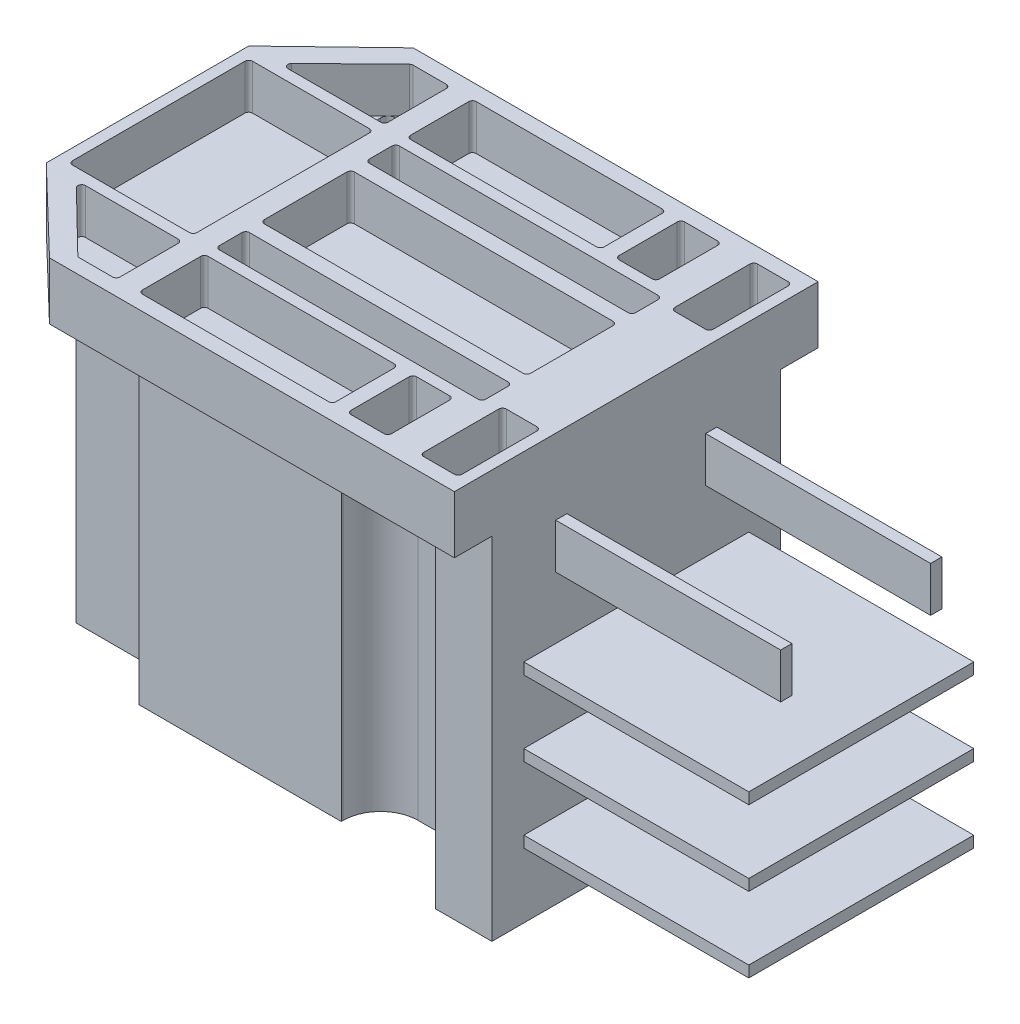
from build123d import *

# Parameters (mm, degrees)
SKETCH_1_W          = 65.18
SKETCH_1_H          = 48.5
EXTRUDE_1_DEPTH     = 7.64
SKETCH_2_W          = 5
SKETCH_2_H          = 4
CUT_EXTRUDE_1_DEPTH = 8.64
FILLET_1_R          = 1
CUT_EXTRUDE_2_DEPTH = 8.64
EXTRUDE_2_DEPTH     = 42
SKETCH_5_W          = 7.5
SKETCH_5_H          = 38.5
EXTRUDE_3_DEPTH     = 46.8
FILLET_2_R          = 5
SKETCH_6_W          = 30
SKETCH_6_H          = 1.5
SKETCH_6_W_2        = 1.5
SKETCH_6_H_2        = 6
EXTRUDE_4_DEPTH     = 30
SKETCH_8_W          = 16.59
SKETCH_8_H          = 24
SKETCH_8_W_2        = 5.4
SKETCH_8_H_2        = 8.75
SKETCH_8_W_3        = 35.5
SKETCH_8_H_3        = 12
SKETCH_8_W_4        = 25.8
SKETCH_8_H_4        = 4
SKETCH_8_W_5        = 5.09
SKETCH_8_H_5        = 11
CUT_EXTRUDE_3_DEPTH = 6
FILLET_3_R          = 0.5


with BuildPart() as part:
    # 草图1 → 凸台-拉伸1 (new body)
    with BuildSketch(Plane(origin=(0, 0, 0), x_dir=(1, 0, 0), z_dir=(0, 1, 0))):
        Rectangle(SKETCH_1_W, SKETCH_1_H)
    extrude(amount=EXTRUDE_1_DEPTH)

    # 草图2 → 切除-拉伸1 (cut, through all)
    with BuildSketch(Plane(origin=(0, 7.64, 0), x_dir=(1, 0, 0), z_dir=(0, 1, 0))):
        with Locations((19, 19)):
            Rectangle(SKETCH_2_W, SKETCH_2_H)
        with Locations((-19, 19)):
            Rectangle(SKETCH_2_W, SKETCH_2_H)
        with Locations((19, -19)):
            Rectangle(SKETCH_2_W, SKETCH_2_H)
        with Locations((-19, -19)):
            Rectangle(SKETCH_2_W, SKETCH_2_H)
    extrude(amount=-CUT_EXTRUDE_1_DEPTH, mode=Mode.SUBTRACT)

    # 圆角1
    fillet_1_edges = [part.edges().sort_by_distance(p)[0] for p in [
        (-16.5, 3.82, 17),
        (-16.5, 3.82, 21),
        (-21.5, 3.82, 21),
        (-21.5, 3.82, 17),
        (16.5, 3.82, 17),
        (21.5, 3.82, 17),
        (21.5, 3.82, 21),
        (16.5, 3.82, 21),
        (16.5, 3.82, -17),
        (16.5, 3.82, -21),
        (21.5, 3.82, -21),
        (21.5, 3.82, -17),
        (-21.5, 3.82, -17),
        (-21.5, 3.82, -21),
        (-16.5, 3.82, -21),
        (-16.5, 3.82, -17),
    ]]
    fillet(fillet_1_edges, radius=FILLET_1_R)

    # 草图3 → 切除-拉伸2 (cut, through all)
    with BuildSketch(Plane(origin=(0, 7.64, 0), x_dir=(1, 0, 0), z_dir=(0, 1, 0))):
        Polygon((-21.41, 24.25), (-32.59, 13.5), (-32.59, 24.25), align=None)
        Polygon((-32.59, -13.5), (-32.59, -24.25), (-21.41, -24.25), align=None)
    extrude(amount=-CUT_EXTRUDE_2_DEPTH, mode=Mode.SUBTRACT)

    # 草图4 → 凸台-拉伸2 (add)
    with BuildSketch(Plane.XZ):
        Polygon((-27.09, -15), (-27.09, 15), (-13.5, 15), (-13.5, 20.25), (13.5, 20.25), (13.5, 15), (25.09, 15), (25.09, -15), (13.5, -15), (13.5, -20.25), (-13.5, -20.25), (-13.5, -15), align=None)
    extrude(amount=EXTRUDE_2_DEPTH)

    # 草图5 → 凸台-拉伸3 (add)
    with BuildSketch(Plane.XZ):
        with Locations((28.84, 0)):
            Rectangle(SKETCH_5_W, SKETCH_5_H)
    extrude(amount=EXTRUDE_3_DEPTH)

    # 圆角2
    fillet_2_edges = [part.edges().sort_by_distance(p)[0] for p in [
        (-13.5, -21, 15),
        (-13.5, -21, -15),
        (13.5, -21, -15),
        (13.5, -21, 15),
    ]]
    fillet(fillet_2_edges, radius=FILLET_2_R)

    # 草图6 → 凸台-拉伸4 (add)
    with BuildSketch(Plane(origin=(32.59, 0, 0), x_dir=(0, 0, -1), z_dir=(1, 0, 0))):
        with Locations((0, -27.4)):
            Rectangle(SKETCH_6_W, SKETCH_6_H)
        with Locations((0, -17.4)):
            Rectangle(SKETCH_6_W, SKETCH_6_H)
        with Locations((0, -37.4)):
            Rectangle(SKETCH_6_W, SKETCH_6_H)
        with Locations((10, -5.4)):
            Rectangle(SKETCH_6_W_2, SKETCH_6_H_2)
        with Locations((-10, -5.4)):
            Rectangle(SKETCH_6_W_2, SKETCH_6_H_2)
    extrude(amount=EXTRUDE_4_DEPTH)

    # 草图8 → 切除-拉伸3 (cut)
    with BuildSketch(Plane(origin=(0, 7.64, 0), x_dir=(1, 0, 0), z_dir=(0, 1, 0))):
        Polygon((-28.59, 13.5), (-14.5, 13.5), (-14.5, 22.25), (-19.626707293, 22.25), align=None)
        with Locations((-22.795, 0)):
            Rectangle(SKETCH_8_W, SKETCH_8_H)
        with Locations((19, 17.875)):
            Rectangle(SKETCH_8_W_2, SKETCH_8_H_2)
        with Locations((6.25, 0)):
            Rectangle(SKETCH_8_W_3, SKETCH_8_H_3)
        with Locations((1.4, 17.875)):
            Rectangle(SKETCH_8_W_4, SKETCH_8_H_2)
        with Locations((6.25, 10)):
            Rectangle(SKETCH_8_W_3, SKETCH_8_H_4)
        with Locations((28.545, 16.75)):
            Rectangle(SKETCH_8_W_5, SKETCH_8_H_5)
        with Locations((28.545, -16.75)):
            Rectangle(SKETCH_8_W_5, SKETCH_8_H_5)
        with Locations((19, -17.875)):
            Rectangle(SKETCH_8_W_2, SKETCH_8_H_2)
        with Locations((6.25, -10)):
            Rectangle(SKETCH_8_W_3, SKETCH_8_H_4)
        with Locations((1.4, -17.875)):
            Rectangle(SKETCH_8_W_4, SKETCH_8_H_2)
        Polygon((-14.5, -22.25), (-19.626707293, -22.25), (-28.59, -13.5), (-14.5, -13.5), align=None)
    extrude(amount=-CUT_EXTRUDE_3_DEPTH, mode=Mode.SUBTRACT)

    # 圆角3
    fillet_3_edges = [part.edges().sort_by_distance(p)[0] for p in [
        (-11.5, 4.64, -8),
        (-11.5, 4.64, -12),
        (24, 4.64, -12),
        (24, 4.64, -8),
        (-11.5, 4.64, -6),
        (24, 4.64, -6),
        (24, 4.64, 6),
        (-11.5, 4.64, 6),
        (26, 4.64, -11.25),
        (26, 4.64, -22.25),
        (31.09, 4.64, -22.25),
        (31.09, 4.64, -11.25),
        (16.3, 4.64, 22.25),
        (16.3, 4.64, 13.5),
        (21.7, 4.64, 13.5),
        (21.7, 4.64, 22.25),
        (16.3, 4.64, -13.5),
        (16.3, 4.64, -22.25),
        (21.7, 4.64, -22.25),
        (21.7, 4.64, -13.5),
        (-14.5, 4.64, -12),
        (-14.5, 4.64, 12),
        (-31.09, 4.64, 12),
        (-31.09, 4.64, -12),
        (26, 4.64, 22.25),
        (26, 4.64, 11.25),
        (31.09, 4.64, 11.25),
        (31.09, 4.64, 22.25),
        (-11.5, 4.64, -13.5),
        (-11.5, 4.64, -22.25),
        (14.3, 4.64, -22.25),
        (14.3, 4.64, -13.5),
        (-11.5, 4.64, 12),
        (-11.5, 4.64, 8),
        (24, 4.64, 8),
        (24, 4.64, 12),
        (-11.5, 4.64, 22.25),
        (-11.5, 4.64, 13.5),
        (14.3, 4.64, 13.5),
        (14.3, 4.64, 22.25),
        (-14.5, 4.64, 13.5),
        (-14.5, 4.64, 22.25),
        (-19.626707293, 4.64, 22.25),
        (-28.59, 4.64, 13.5),
        (-28.59, 4.64, -13.5),
        (-19.626707293, 4.64, -22.25),
        (-14.5, 4.64, -22.25),
        (-14.5, 4.64, -13.5),
    ]]
    fillet(fillet_3_edges, radius=FILLET_3_R)


solid = part.part
